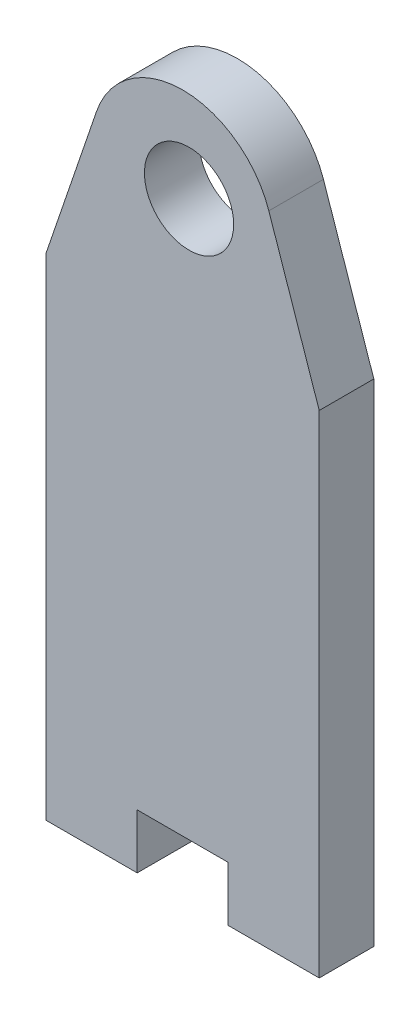
from build123d import *

# Parameters (mm, degrees)
MODEL_R                 = 2.45
SALIENTE_EXTRUIR1_DEPTH = 3


with BuildPart() as part:
    # Model → Saliente-Extruir1 (new body)
    with BuildSketch(Plane.XY):
        with BuildLine():
            Line((47.732278764, 49.864167804), (50.5, 41.75))
            Line((50.5, 41.75), (50.5, 27.75))
            Line((50.5, 27.75), (50.5, 14.75))
            Line((50.5, 14.75), (45.5, 14.75))
            Line((45.5, 14.75), (45.5, 17.75))
            Line((45.5, 17.75), (40.5, 17.75))
            Line((40.5, 17.75), (40.5, 14.75))
            Line((40.5, 14.75), (35.5, 14.75))
            Line((35.5, 14.75), (35.5, 27.75))
            Line((35.5, 27.75), (35.5, 41.75))
            Line((35.5, 41.75), (38.267721236, 49.864167804))
            ThreePointArc((38.267721236, 49.864167804), (43, 53.25), (47.732278764, 49.864167804))
        make_face()
        with Locations((43.348582377, 48.25)):
            Circle(MODEL_R, mode=Mode.SUBTRACT)
    extrude(amount=SALIENTE_EXTRUIR1_DEPTH)


solid = part.part
